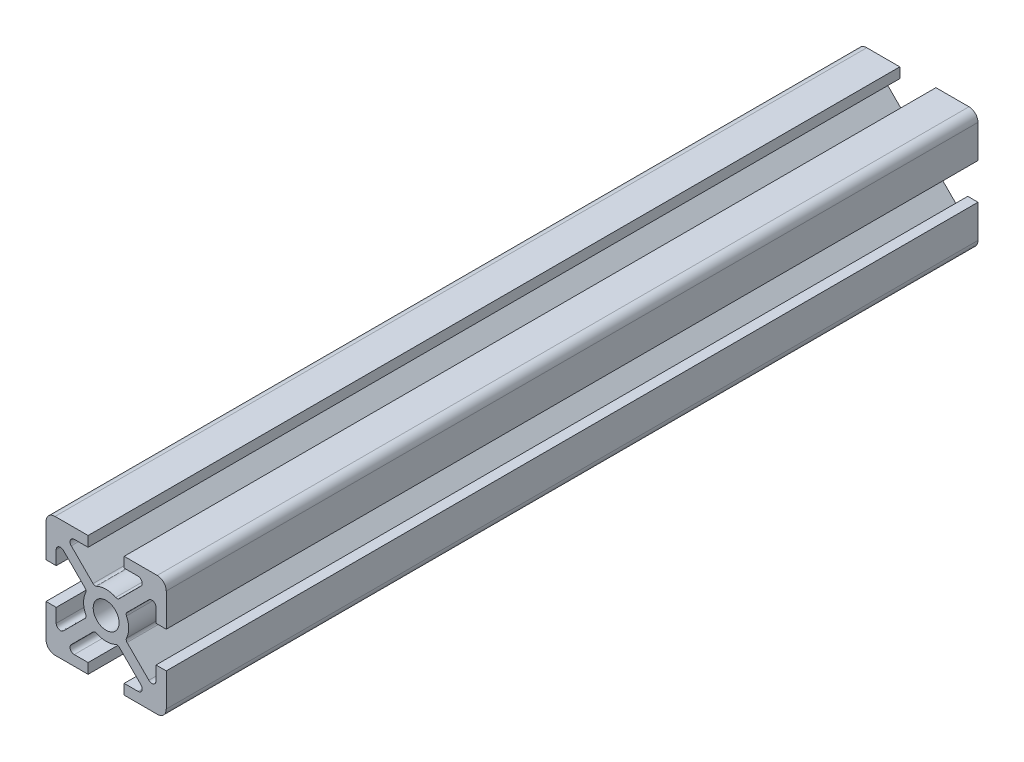
from build123d import *

# Parameters (mm, degrees)
ESQUISSE1_R        = 2.15
BOSS_EXTRU_1_DEPTH = 135


with BuildPart() as part:
    # Esquisse1 → Boss.-Extru.1 (new body)
    with BuildSketch(Plane.XY):
        with BuildLine():
            Line((-3, 10), (-8.5, 10))
            ThreePointArc((-8.5, 10), (-9.560660172, 9.560660172), (-10, 8.5))
            Line((-10, 8.5), (-10, 3))
            Line((-10, 3), (-8.300000103, 3))
            Line((-8.300000103, 3), (-8.300000103, 5.299391013))
            ThreePointArc((-8.300000103, 5.299391013), (-7.867878523, 5.946106661), (-7.105025403, 5.794365741))
            Line((-7.105025403, 5.794365741), (-3.486125569, 2.175465907))
            ThreePointArc((-3.486125569, 2.175465907), (-3.346986783, 1.907085393), (-3.38795202, 1.607569866))
            ThreePointArc((-3.38795202, 1.607569866), (-3.749999968, 1.37e-07), (-3.387952137, -1.607569618))
            ThreePointArc((-3.387952137, -1.607569618), (-3.346986918, -1.907085124), (-3.486125693, -2.175465617))
            Line((-3.486125693, -2.175465617), (-7.10502539, -5.794365497))
            ThreePointArc((-7.10502539, -5.794365497), (-7.867878514, -5.946106433), (-8.300000103, -5.299390782))
            Line((-8.300000103, -5.299390782), (-8.300000103, -3))
            Line((-8.300000103, -3), (-10, -3))
            Line((-10, -3), (-10, -8.5))
            ThreePointArc((-10, -8.5), (-9.560660172, -9.560660172), (-8.5, -10))
            Line((-8.5, -10), (-3, -10))
            Line((-3, -10), (-3, -8.29999992))
            Line((-3, -8.29999992), (-5.299390173, -8.29999992))
            ThreePointArc((-5.299390173, -8.29999992), (-5.94610582, -7.867878342), (-5.794364905, -7.105025224))
            Line((-5.794364905, -7.105025224), (-2.175465502, -3.486125765))
            ThreePointArc((-2.175465502, -3.486125765), (-1.907085014, -3.346986981), (-1.607569506, -3.38795219))
            ThreePointArc((-1.607569506, -3.38795219), (1.99e-07, -3.749999968), (1.607569866, -3.38795202))
            ThreePointArc((1.607569866, -3.38795202), (1.907085393, -3.346986783), (2.175465907, -3.486125569))
            Line((2.175465907, -3.486125569), (5.794365558, -7.10502522))
            ThreePointArc((5.794365558, -7.10502522), (5.946106478, -7.86787834), (5.29939083, -8.29999992))
            Line((5.29939083, -8.29999992), (3, -8.29999992))
            Line((3, -8.29999992), (3, -10))
            Line((3, -10), (8.499999896, -10))
            ThreePointArc((8.499999896, -10), (9.560660068, -9.560660172), (9.999999896, -8.5))
            Line((9.999999896, -8.5), (9.999999896, -3))
            Line((9.999999896, -3), (8.300000103, -3))
            Line((8.300000103, -3), (8.300000103, -5.299391569))
            ThreePointArc((8.300000103, -5.299391569), (7.867878509, -5.946107222), (7.105025381, -5.794366275))
            Line((7.105025381, -5.794366275), (3.486125475, -2.175466057))
            ThreePointArc((3.486125475, -2.175466057), (3.346986701, -1.907085538), (3.38795195, -1.607570012))
            ThreePointArc((3.38795195, -1.607570012), (3.658368452, -0.823917488), (3.749999968, 0))
            ThreePointArc((3.749999968, 0), (3.658368507, 0.823917244), (3.387952165, 1.607569559))
            ThreePointArc((3.387952165, 1.607569559), (3.346986951, 1.907085066), (3.486125731, 2.175465556))
            Line((3.486125731, 2.175465556), (7.105025399, 5.79436528))
            ThreePointArc((7.105025399, 5.79436528), (7.86787852, 5.946106205), (8.300000103, 5.299390557))
            Line((8.300000103, 5.299390557), (8.300000103, 3))
            Line((8.300000103, 3), (9.999999896, 3))
            Line((9.999999896, 3), (9.999999896, 8.5))
            ThreePointArc((9.999999896, 8.5), (9.560660068, 9.560660172), (8.499999896, 10))
            Line((8.499999896, 10), (3.499999896, 10))
            Line((3.499999896, 10), (3, 10))
            Line((3, 10), (3, 8.29999992))
            Line((3, 8.29999992), (5.299389948, 8.29999992))
            ThreePointArc((5.299389948, 8.29999992), (5.946105592, 7.867878348), (5.794364688, 7.105025232))
            Line((5.794364688, 7.105025232), (2.175465441, 3.486125803))
            ThreePointArc((2.175465441, 3.486125803), (1.907084956, 3.346987014), (1.607569447, 3.387952218))
            ThreePointArc((1.607569447, 3.387952218), (-1.51e-07, 3.749999968), (-1.60756972, 3.387952089))
            ThreePointArc((-1.60756972, 3.387952089), (-1.907085249, 3.346986865), (-2.175465757, 3.486125663))
            Line((-2.175465757, 3.486125663), (-5.794365024, 7.105025241))
            ThreePointArc((-5.794365024, 7.105025241), (-5.946105917, 7.867878353), (-5.299390275, 8.29999992))
            Line((-5.299390275, 8.29999992), (-3, 8.29999992))
            Line((-3, 8.29999992), (-3, 10))
        make_face()
        Circle(ESQUISSE1_R, mode=Mode.SUBTRACT)
    extrude(amount=BOSS_EXTRU_1_DEPTH)


solid = part.part
